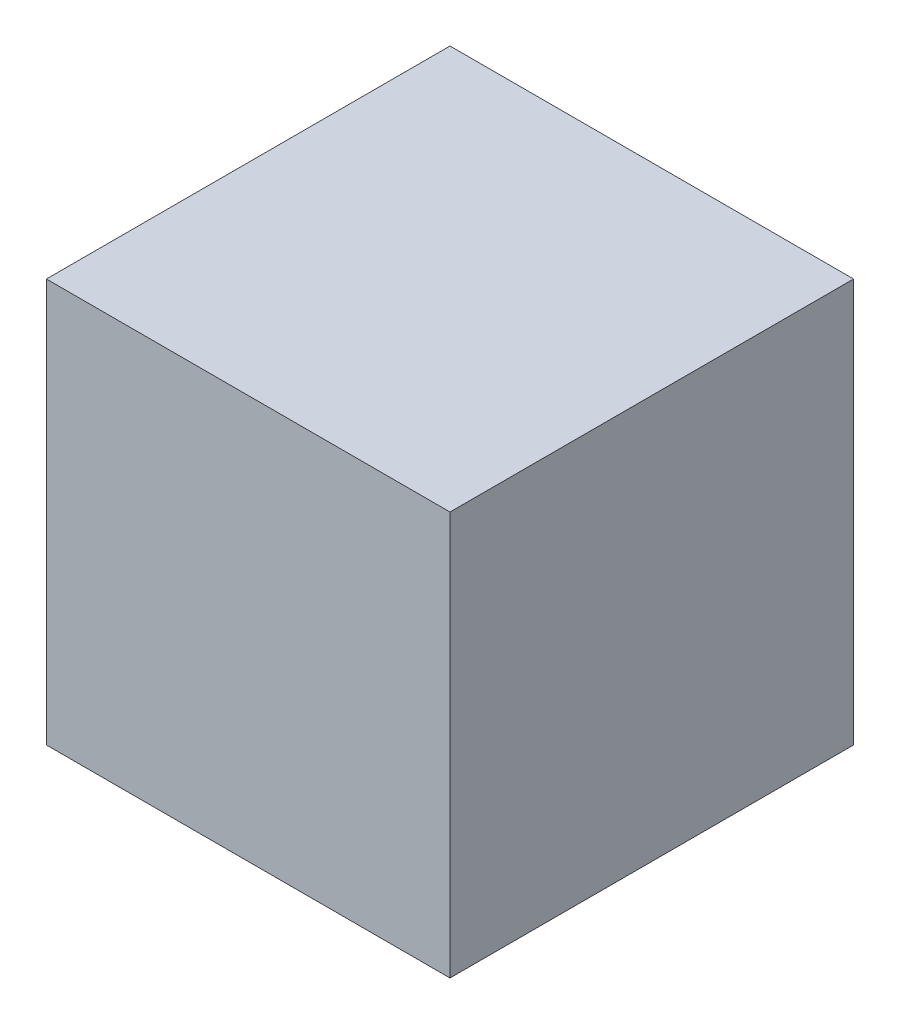
from build123d import *

# Parameters (mm, degrees)
SKETCH_1_W      = 40
SKETCH_1_H      = 40
EXTRUDE_1_DEPTH = 40


with BuildPart() as part:
    # 草图1 → 凸台-拉伸1 (new body)
    with BuildSketch(Plane.XY):
        with Locations((2.51497006, -9.98003992)):
            Rectangle(SKETCH_1_W, SKETCH_1_H)
    extrude(amount=EXTRUDE_1_DEPTH)


solid = part.part
